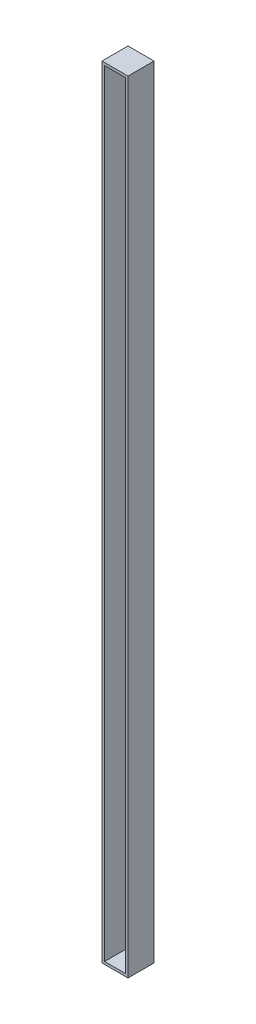
from build123d import *

# Parameters (mm, degrees)
SKETCH1_W           = 20
SKETCH1_H           = 600
BOSS_EXTRUDE1_DEPTH = 20
SKETCH2_W           = 16
SKETCH2_H           = 596
CUT_EXTRUDE1_DEPTH  = 18


with BuildPart() as part:
    # Sketch1 → Boss-Extrude1 (new body)
    with BuildSketch(Plane.XY):
        with Locations((-21.739130435, -250.217391304)):
            Rectangle(SKETCH1_W, SKETCH1_H)
    extrude(amount=-BOSS_EXTRUDE1_DEPTH)

    # Sketch2 → Cut-Extrude1 (cut)
    with BuildSketch(Plane.XY):
        with Locations((-21.739130435, -250.217391304)):
            Rectangle(SKETCH2_W, SKETCH2_H)
    extrude(amount=-CUT_EXTRUDE1_DEPTH, mode=Mode.SUBTRACT)


solid = part.part
